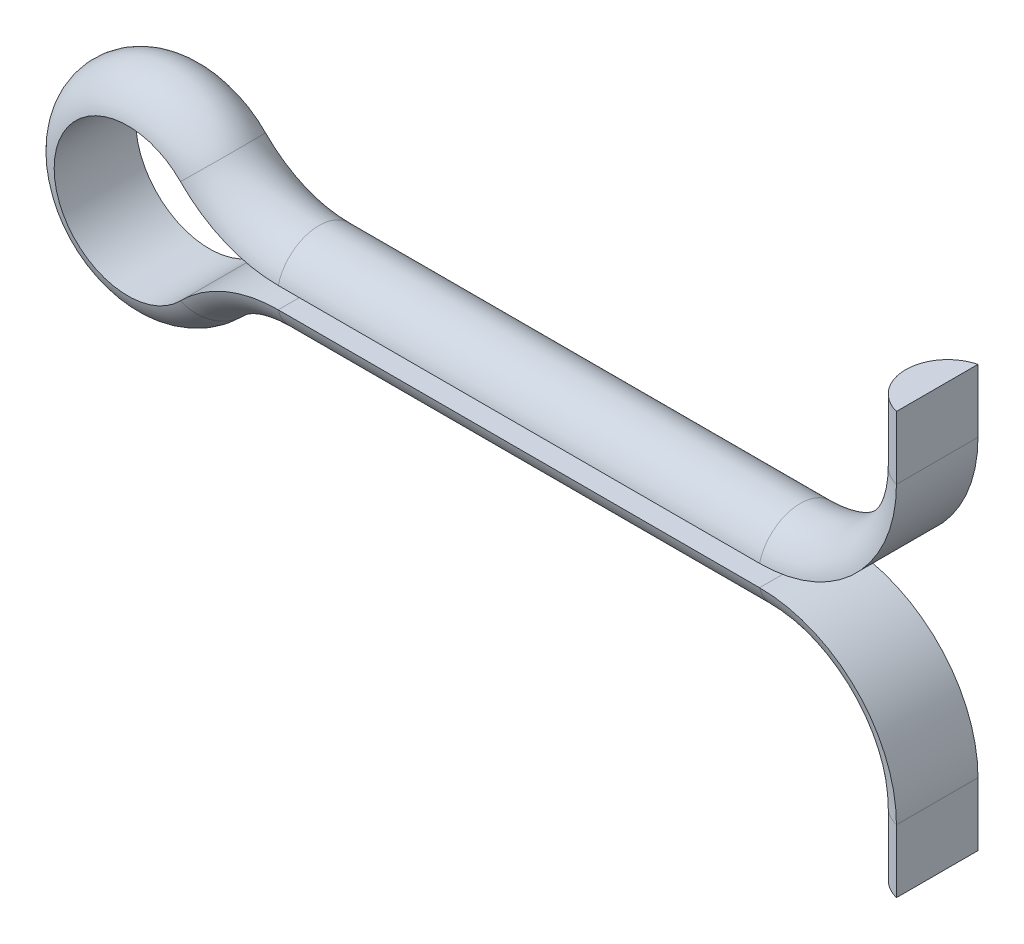
from build123d import *


with BuildPart() as part:
    # Táhnout po křivce1: sweep along a path in Skica2
    with BuildLine(Plane.XY) as t_hnout_po_k_ivce1_path:
        Line((35, 10), (35, 7))
        ThreePointArc((35, 7), (33.535533906, 3.464466094), (30, 2))
        Line((30, 2), (7.141428429, 2))
        ThreePointArc((7.141428429, 2), (5.204936755, 2.390227771), (3.570714214, 3.5))
        ThreePointArc((3.570714214, 3.5), (-5, 0), (3.570714214, -3.5))
        ThreePointArc((3.570714214, -3.5), (5.204936755, -2.390227771), (7.141428429, -2))
        Line((7.141428429, -2), (30, -2))
        ThreePointArc((30, -2), (33.535533906, -3.464466094), (35, -7))
        Line((35, -7), (35, -10))
    # Skica4 → Táhnout po křivce1 (sweep)
    with BuildSketch(Plane(origin=(35, 10, 0), x_dir=(-1, 0, 0), z_dir=(0, -1, 0))):
        with BuildLine():
            Line((-1.5, 1.936491673), (-1.5, -1.936491673))
            ThreePointArc((-1.5, -1.936491673), (0, 0), (-1.5, 1.936491673))
        make_face()
    sweep(path=t_hnout_po_k_ivce1_path.line)


solid = part.part
